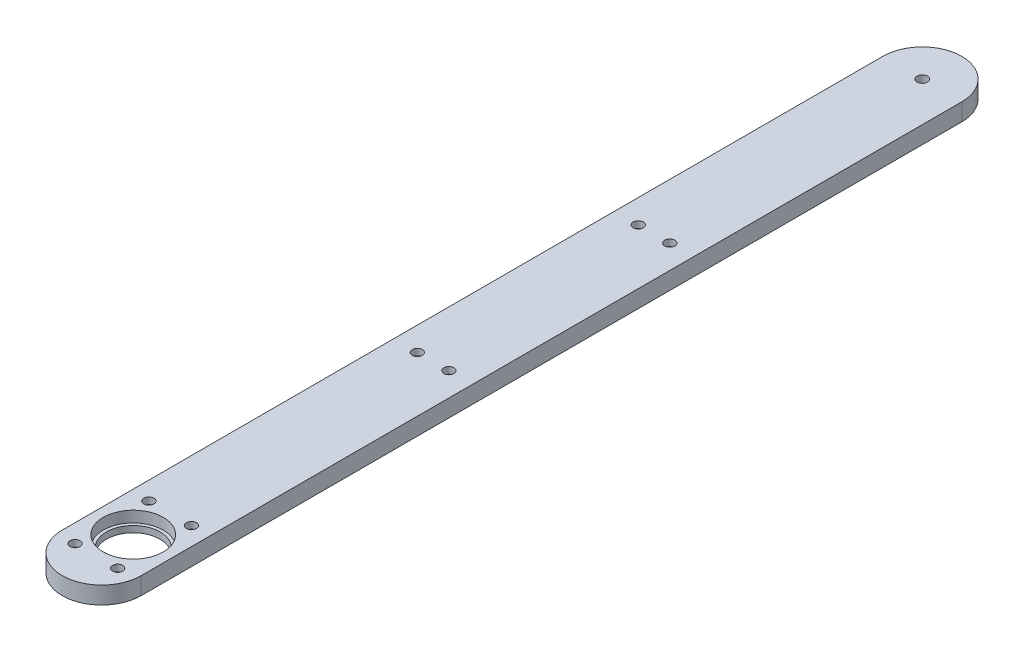
from build123d import *

# Parameters (mm, degrees)
EXTRUDE_1_DEPTH              = 10.5
EXTRUDE_1_DEPTH_BACK         = 10.5
SKETCH_1_R                   = 5
EXTRUDE_3_DEPTH              = 4.5
EXTRUDE_3_DEPTH_BACK         = 4.5
SKETCH_7_R                   = 6
EXTRUDE_4_DEPTH              = 3
EXTRUDE_START                = 3
SKETCH_8_R                   = 6
EXTRUDE_5_DEPTH              = 3
SKETCH_9_R                   = 9.5
CUT_EXTRUDE_1_DEPTH          = 7
SKETCH_10_R                  = 8.5
CUT_EXTRUDE_2_DEPTH          = 274.096136919
HOLE_WIZARD_M4_1_D           = 3.3
SKETCH_22_W                  = 47.656916312
SKETCH_22_H                  = 14.908676054
CUT_EXTRUDE_3_DEPTH          = 1111
SKETCH_23_R                  = 9.5
SKETCH_23_R_2                = 8.5
EXTRUDE_6_DEPTH              = 2
HOLE_WIZARD_M3_1_D           = 3.2
HOLE_WIZARD_M3_1_CBORE_D     = 6.5
HOLE_WIZARD_M3_1_CBORE_DEPTH = 3.4
PATTERN_CIRCULAR_1_COUNT     = 6
HOLE_WIZARD_M3_2_D           = 3.2
HOLE_WIZARD_M3_2_CBORE_D     = 6.5
HOLE_WIZARD_M3_2_CBORE_DEPTH = 3.4
PATTERN_LINEAR_1_COUNT       = 3
PATTERN_LINEAR_1_PITCH       = 70
PATTERN_LINEAR_1_COUNT_DIR2  = 2
PATTERN_LINEAR_1_PITCH_DIR2  = 10
SKETCH_31_R                  = 3.25
EXTRUDE_7_DEPTH              = 5.5


with BuildPart() as part:
    # 스케치1 → 보스-돌출1 (new, two sides: drawn at the far end of the back side and taken through both)
    with BuildSketch(Plane(origin=(0, 0, 0), x_dir=(1, 0, 0), z_dir=(0, 1, 0)).offset(-EXTRUDE_1_DEPTH_BACK)):
        Circle(SKETCH_1_R)
    extrude(amount=EXTRUDE_1_DEPTH + EXTRUDE_1_DEPTH_BACK)

    # 스케치6 → 보스-돌출3 (add, two sides: drawn at the far end of the back side and taken through both)
    with BuildSketch(Plane(origin=(0, 0, 0), x_dir=(1, 0, 0), z_dir=(0, 1, 0)).offset(-EXTRUDE_3_DEPTH_BACK)):
        with BuildLine():
            Line((-12.5, 0), (-12.5, -260))
            ThreePointArc((-12.5, -260), (0, -272.5), (12.5, -260))
            Line((12.5, -260), (12.5, 0))
            ThreePointArc((12.5, 0), (0, 12.5), (-12.5, 0))
        make_face()
    extrude(amount=EXTRUDE_3_DEPTH + EXTRUDE_3_DEPTH_BACK)

    # 스케치7 → 보스-돌출4 (add)
    with BuildSketch(Plane.XZ.offset(4.5)):
        Circle(SKETCH_7_R)
    extrude(amount=EXTRUDE_4_DEPTH)

    # 스케치8 → 보스-돌출5 (add)
    with BuildSketch(Plane(origin=(0, 4.5, 0), x_dir=(1, 0, 0), z_dir=(0, 1, 0)).offset(EXTRUDE_START)):
        Circle(SKETCH_8_R)
    extrude(amount=-EXTRUDE_5_DEPTH)

    # 스케치9 → 컷-돌출1 (cut)
    with BuildSketch(Plane.XZ.offset(4.5)):
        with Locations((0, 250)):
            Circle(SKETCH_9_R)
    extrude(amount=-CUT_EXTRUDE_1_DEPTH, mode=Mode.SUBTRACT)

    # 스케치10 → 컷-돌출2 (cut, through all)
    with BuildSketch(Plane.XZ.offset(-2.5)):
        with Locations((0, 250)):
            Circle(SKETCH_10_R)
    extrude(amount=-CUT_EXTRUDE_2_DEPTH, mode=Mode.SUBTRACT)

    # M4 탭을 위한 탭 드릴1 (through all)
    with Locations(Plane(origin=(0, -10.5, 0), x_dir=(-1, 0, 0), z_dir=(0, -1, 0))):
        with Locations((0, 0)):
            Hole(HOLE_WIZARD_M4_1_D / 2)

    # 스케치22 → 컷-돌출3 (cut, symmetric)
    with BuildSketch(Plane.XY):
        with Locations((0.455125877, 8.454338027)):
            Rectangle(SKETCH_22_W, SKETCH_22_H)
    extrude(amount=CUT_EXTRUDE_3_DEPTH, both=True, mode=Mode.SUBTRACT)

    # 스케치23 → 보스-돌출6 (add)
    with BuildSketch(Plane.XZ.offset(4.5)):
        with Locations((0, 250)):
            Circle(SKETCH_23_R)
        with Locations((0, 250)):
            Circle(SKETCH_23_R_2, mode=Mode.SUBTRACT)
    extrude(amount=-EXTRUDE_6_DEPTH)

    # M3 육각 소켓 머리 캡 나사용 카운터보어1 (through all)
    with Locations(Plane(origin=(0, -4.5, 0), x_dir=(-1, 0, 0), z_dir=(0, -1, 0))):
        with Locations((6.75, -261.691342951)):
            hole_wizard_m3_1 = CounterBoreHole(HOLE_WIZARD_M3_1_D / 2, HOLE_WIZARD_M3_1_CBORE_D / 2, HOLE_WIZARD_M3_1_CBORE_DEPTH)

    # 원형 패턴1: M3 육각 소켓 머리 캡 나사용 카운터보어1 ×6 about axis, 2 skipped
    pattern_circular_1_axis = Axis((0, -2.5, 250), (0, -1, 0))
    add([hole_wizard_m3_1.rotate(pattern_circular_1_axis, i * 360 / PATTERN_CIRCULAR_1_COUNT) for i in range(1, PATTERN_CIRCULAR_1_COUNT) if i not in (1, 4)], mode=Mode.SUBTRACT)

    # M3 육각 소켓 머리 캡 나사용 카운터보어2 (through all)
    with Locations(Plane(origin=(0, -4.5, 0), x_dir=(-1, 0, 0), z_dir=(0, -1, 0))):
        with Locations((5, -15)):
            hole_wizard_m3_2 = CounterBoreHole(HOLE_WIZARD_M3_2_D / 2, HOLE_WIZARD_M3_2_CBORE_D / 2, HOLE_WIZARD_M3_2_CBORE_DEPTH)

    # 선형 패턴1: Hole Wizard M3 _ _ _ _ _ _2 3 × 2
    with Locations(*[(j * PATTERN_LINEAR_1_PITCH_DIR2, 0, i * PATTERN_LINEAR_1_PITCH) for i in range(PATTERN_LINEAR_1_COUNT) for j in range(PATTERN_LINEAR_1_COUNT_DIR2) if (i, j) != (0, 0)]):
        add(hole_wizard_m3_2, mode=Mode.SUBTRACT)

    # 스케치31 → 보스-돌출7 (add)
    with BuildSketch(Plane.XZ.offset(4.5)):
        with Locations((5, 15)):
            Circle(SKETCH_31_R)
        with Locations((-5, 15)):
            Circle(SKETCH_31_R)
    extrude(amount=-EXTRUDE_7_DEPTH)


solid = part.part
